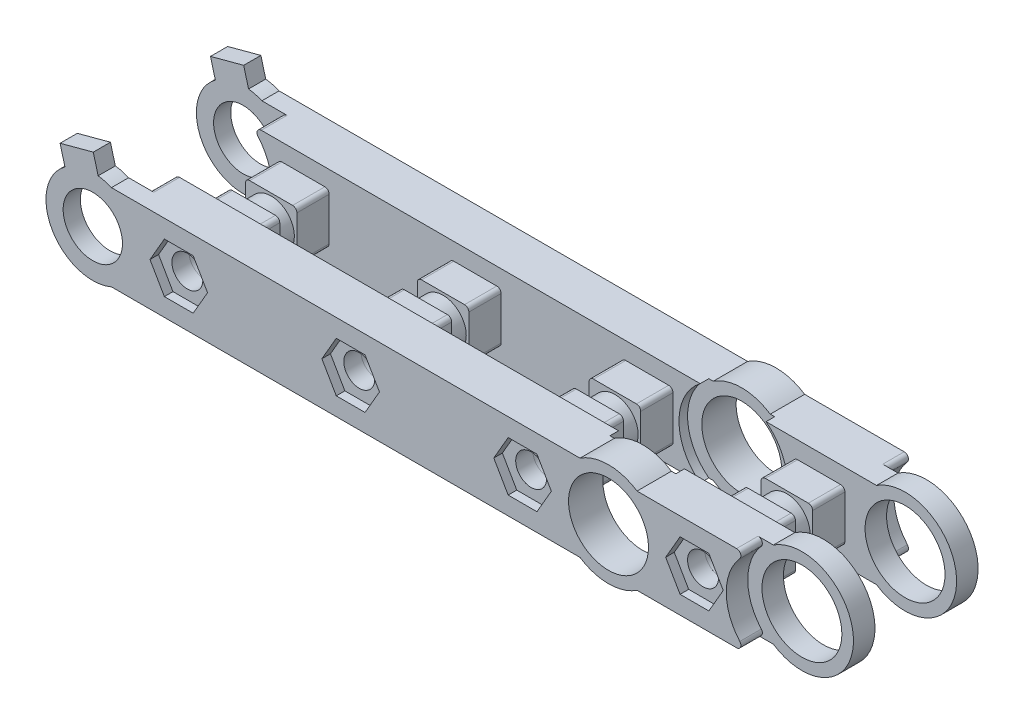
from build123d import *

# Parameters (mm, degrees)
SKETCH_1_R               = 1.8
SKETCH_1_R_2             = 4.39
SKETCH_1_R_3             = 3.45
EXTRUDE_1_DEPTH          = 2
SKETCH_2_R               = 1.8
SKETCH_2_R_2             = 4.39
EXTRUDE_2_DEPTH          = 3
EXTRUDE_3_DEPTH          = 2
SKETCH_4_R               = 1.8
SKETCH_4_R_2             = 3.45
SKETCH_4_R_3             = 4.39
EXTRUDE_4_DEPTH          = 2
SKETCH_5_R               = 1.8
SKETCH_5_R_2             = 4.39
EXTRUDE_5_DEPTH          = 3
SKETCH_12_R              = 6.3
CUT_EXTRUDE_5_DEPTH      = 2.5
SKETCH_14_R              = 6.3
CUT_EXTRUDE_7_DEPTH      = 1
FILLET_1_R               = 0.5
SKETCH_15_R              = 6.3
CUT_EXTRUDE_8_DEPTH      = 2.5
SKETCH_16_R              = 6.3
CUT_EXTRUDE_9_DEPTH      = 1
FILLET_2_R               = 0.5
EXTRUDE_6_DEPTH          = 2
SKETCH_7_W               = 6.2
SKETCH_7_H               = 6.2
CUT_EXTRUDE_1_DEPTH      = 2
SKETCH_8_W               = 6
SKETCH_8_H               = 6
SKETCH_8_R               = 1.8
EXTRUDE_7_DEPTH          = 11.5
SKETCH_9_W               = 6
SKETCH_9_H               = 6
SKETCH_9_R               = 2.7
CUT_EXTRUDE_2_DEPTH      = 1
CUT_EXTRUDE_2_DEPTH_BACK = 1
CUT_EXTRUDE_3_DEPTH      = 1
SKETCH_11_R              = 3.25
CUT_EXTRUDE_4_DEPTH      = 1.5
SKETCH_17_R              = 4.65
CUT_EXTRUDE_10_DEPTH     = 20.5
SKETCH_18_R              = 6.3
CUT_EXTRUDE_11_DEPTH     = 1
SKETCH_19_R              = 6.3
CUT_EXTRUDE_12_DEPTH     = 1
EXTRUDE_8_DEPTH          = 4
EXTRUDE_9_DEPTH          = 4
SKETCH_22_R              = 4.39
EXTRUDE_10_DEPTH         = 1
SKETCH_23_R              = 4.39
EXTRUDE_11_DEPTH         = 1
FILLET_3_R               = 0.5
SKETCH_24_R              = 4.65
CUT_EXTRUDE_13_DEPTH     = 18


with BuildPart() as part:
    # ｽｹｯﾁ1 → ﾎﾞｽ - 押し出し1 (new body)
    with BuildSketch(Plane.XY):
        with BuildLine():
            Line((-77.831475156, 5), (-60, 5))
            Line((-60, 5), (-40, 5))
            Line((-40, 5), (-20, 5))
            Line((-20, 5), (-3.31662479, 5))
            ThreePointArc((-3.31662479, 5), (6, 0), (-3.31662479, -5))
            Line((-3.31662479, -5), (-20, -5))
            Line((-20, -5), (-40, -5))
            Line((-40, -5), (-60, -5))
            Line((-60, -5), (-77.831475156, -5))
            ThreePointArc((-77.831475156, -5), (-85.45, 0), (-77.831475156, 5))
        make_face()
        with Locations((-10, 0)):
            Circle(SKETCH_1_R, mode=Mode.SUBTRACT)
        with Locations((-30, 0)):
            Circle(SKETCH_1_R, mode=Mode.SUBTRACT)
        with Locations((-50, 0)):
            Circle(SKETCH_1_R, mode=Mode.SUBTRACT)
        with Locations((-70, 0)):
            Circle(SKETCH_1_R, mode=Mode.SUBTRACT)
        Circle(SKETCH_1_R_2, mode=Mode.SUBTRACT)
        with Locations((-80, 0)):
            Circle(SKETCH_1_R_3, mode=Mode.SUBTRACT)
    extrude(amount=EXTRUDE_1_DEPTH)

    # ｽｹｯﾁ2 → ﾎﾞｽ - 押し出し2 (add)
    with BuildSketch(Plane(origin=(0, 0, 0), x_dir=(-1, 0, 0), z_dir=(0, 0, -1))):
        with BuildLine():
            Line((74.901961161, 5), (60, 5))
            Line((60, 5), (40, 5))
            Line((40, 5), (20, 5))
            Line((20, 5), (3.31662479, 5))
            ThreePointArc((3.31662479, 5), (-6, 0), (3.31662479, -5))
            Line((3.31662479, -5), (20, -5))
            Line((20, -5), (40, -5))
            Line((40, -5), (60, -5))
            Line((60, -5), (74.901961161, -5))
            ThreePointArc((74.901961161, -5), (75.357724903, -4.70561958), (75.276816958, -4.169117647))
            ThreePointArc((75.276816958, -4.169117647), (73.7, 0), (75.276816958, 4.169117647))
            ThreePointArc((75.276816958, 4.169117647), (75.357724903, 4.70561958), (74.901961161, 5))
        make_face()
        with Locations((30, 0)):
            Circle(SKETCH_2_R, mode=Mode.SUBTRACT)
        with Locations((10, 0)):
            Circle(SKETCH_2_R, mode=Mode.SUBTRACT)
        with Locations((70, 0)):
            Circle(SKETCH_2_R, mode=Mode.SUBTRACT)
        with Locations((50, 0)):
            Circle(SKETCH_2_R, mode=Mode.SUBTRACT)
        Circle(SKETCH_2_R_2, mode=Mode.SUBTRACT)
    extrude(amount=EXTRUDE_2_DEPTH)

    # ｽｹｯﾁ3 → ﾎﾞｽ - 押し出し3 (add)
    with BuildSketch(Plane.XY.offset(2)):
        Polygon((-79.944586424, 7.520600331), (-79.012837862, 4.043267356), (-82.876541167, 3.007991176), (-83.80828973, 6.48532415), align=None)
    extrude(amount=-EXTRUDE_3_DEPTH)

    # ｽｹｯﾁ12 → ｶｯﾄ - 押し出し5 (cut)
    with BuildSketch(Plane.XY.offset(2)):
        Circle(SKETCH_12_R)
    extrude(amount=-CUT_EXTRUDE_5_DEPTH, mode=Mode.SUBTRACT)

    # ｽｹｯﾁ14 → ｶｯﾄ - 押し出し7 (cut)
    with BuildSketch(Plane(origin=(0, 0, -3), x_dir=(-1, 0, 0), z_dir=(0, 0, -1))):
        Circle(SKETCH_14_R)
    extrude(amount=-CUT_EXTRUDE_7_DEPTH, mode=Mode.SUBTRACT)

    # ﾌｨﾚｯﾄ1
    fillet_1_edges = [part.edges().sort_by_distance(p)[0] for p in [
        (-3.832753579, -5, 0.75),
        (-3.832753579, 5, 0.75),
        (-3.832753579, 5, -2.5),
        (-3.832753579, -5, -2.5),
    ]]
    fillet(fillet_1_edges, radius=FILLET_1_R)

    # ｽｹｯﾁ7 → ｶｯﾄ - 押し出し1 (cut)
    with BuildSketch(Plane(origin=(0, 0, -3), x_dir=(-1, 0, 0), z_dir=(0, 0, -1))):
        with Locations((30, 0)):
            Rectangle(SKETCH_7_W, SKETCH_7_H)
        with Locations((10, 0)):
            Rectangle(SKETCH_7_W, SKETCH_7_H)
        with Locations((50, 0)):
            Rectangle(SKETCH_7_W, SKETCH_7_H)
        with Locations((70, 0)):
            Rectangle(SKETCH_7_W, SKETCH_7_H)
    extrude(amount=-CUT_EXTRUDE_1_DEPTH, mode=Mode.SUBTRACT)

    # ｽｹｯﾁ10 → ｶｯﾄ - 押し出し3 (cut)
    with BuildSketch(Plane.XY.offset(2)):
        Polygon((-11.674315781, 2.9), (-13.348631561, 0), (-11.674315781, -2.9), (-8.325684219, -2.9), (-6.651368439, 0), (-8.325684219, 2.9), align=None)
        Polygon((-31.674315781, -2.9), (-28.325684219, -2.9), (-26.651368439, 0), (-28.325684219, 2.9), (-31.674315781, 2.9), (-33.348631561, 0), align=None)
        Polygon((-51.674315781, -2.9), (-48.325684219, -2.9), (-46.651368439, 0), (-48.325684219, 2.9), (-51.674315781, 2.9), (-53.348631561, 0), align=None)
        Polygon((-68.325684219, -2.9), (-66.651368439, 0), (-68.325684219, 2.9), (-71.674315781, 2.9), (-73.348631561, 0), (-71.674315781, -2.9), align=None)
    extrude(amount=-CUT_EXTRUDE_3_DEPTH, mode=Mode.SUBTRACT)


with BuildPart() as body_2:
    # ｽｹｯﾁ4 → ﾎﾞｽ - 押し出し4 (new body)
    with BuildSketch(Plane.XY.offset(-17.5)):
        with BuildLine():
            Line((-60, 5), (-77.831475156, 5))
            ThreePointArc((-77.831475156, 5), (-85.45, 0), (-77.831475156, -5))
            Line((-77.831475156, -5), (-60, -5))
            Line((-60, -5), (-40, -5))
            Line((-40, -5), (-20, -5))
            Line((-20, -5), (-3.31662479, -5))
            ThreePointArc((-3.31662479, -5), (6, 0), (-3.31662479, 5))
            Line((-3.31662479, 5), (-20, 5))
            Line((-20, 5), (-40, 5))
            Line((-40, 5), (-60, 5))
        make_face()
        with Locations((-30, 0)):
            Circle(SKETCH_4_R, mode=Mode.SUBTRACT)
        with Locations((-10, 0)):
            Circle(SKETCH_4_R, mode=Mode.SUBTRACT)
        with Locations((-80, 0)):
            Circle(SKETCH_4_R_2, mode=Mode.SUBTRACT)
        with Locations((-70, 0)):
            Circle(SKETCH_4_R, mode=Mode.SUBTRACT)
        with Locations((-50, 0)):
            Circle(SKETCH_4_R, mode=Mode.SUBTRACT)
        Circle(SKETCH_4_R_3, mode=Mode.SUBTRACT)
    extrude(amount=EXTRUDE_4_DEPTH)

    # ｽｹｯﾁ5 → ﾎﾞｽ - 押し出し5 (add)
    with BuildSketch(Plane.XY.offset(-15.5)):
        with BuildLine():
            Line((-74.901961161, -5), (-60, -5))
            Line((-60, -5), (-40, -5))
            Line((-40, -5), (-20, -5))
            Line((-20, -5), (-3.31662479, -5))
            ThreePointArc((-3.31662479, -5), (6, 0), (-3.31662479, 5))
            Line((-3.31662479, 5), (-20, 5))
            Line((-20, 5), (-40, 5))
            Line((-40, 5), (-60, 5))
            Line((-60, 5), (-74.901961161, 5))
            ThreePointArc((-74.901961161, 5), (-75.357724903, 4.70561958), (-75.276816958, 4.169117647))
            ThreePointArc((-75.276816958, 4.169117647), (-73.7, 0), (-75.276816958, -4.169117647))
            ThreePointArc((-75.276816958, -4.169117647), (-75.357724903, -4.70561958), (-74.901961161, -5))
        make_face()
        with Locations((-10, 0)):
            Circle(SKETCH_5_R, mode=Mode.SUBTRACT)
        with Locations((-30, 0)):
            Circle(SKETCH_5_R, mode=Mode.SUBTRACT)
        with Locations((-50, 0)):
            Circle(SKETCH_5_R, mode=Mode.SUBTRACT)
        with Locations((-70, 0)):
            Circle(SKETCH_5_R, mode=Mode.SUBTRACT)
        Circle(SKETCH_5_R_2, mode=Mode.SUBTRACT)
    extrude(amount=EXTRUDE_5_DEPTH)

    # ｽｹｯﾁ15 → ｶｯﾄ - 押し出し8 (cut)
    with BuildSketch(Plane(origin=(0, 0, -17.5), x_dir=(-1, 0, 0), z_dir=(0, 0, -1))):
        Circle(SKETCH_15_R)
    extrude(amount=-CUT_EXTRUDE_8_DEPTH, mode=Mode.SUBTRACT)

    # ｽｹｯﾁ16 → ｶｯﾄ - 押し出し9 (cut)
    with BuildSketch(Plane.XY.offset(-12.5)):
        Circle(SKETCH_16_R)
    extrude(amount=-CUT_EXTRUDE_9_DEPTH, mode=Mode.SUBTRACT)

    # ﾌｨﾚｯﾄ2
    fillet_2_edges = [body_2.edges().sort_by_distance(p)[0] for p in [
        (-3.832753579, -5, -16.25),
        (-3.832753579, -5, -13),
        (-3.832753579, 5, -13),
        (-3.832753579, 5, -16.25),
    ]]
    fillet(fillet_2_edges, radius=FILLET_2_R)

    # ｽｹｯﾁ6 → ﾎﾞｽ - 押し出し6 (add)
    with BuildSketch(Plane(origin=(0, 0, -17.5), x_dir=(-1, 0, 0), z_dir=(0, 0, -1))):
        Polygon((79.944586424, 7.520600331), (79.012837862, 4.043267356), (82.876541167, 3.007991176), (83.80828973, 6.48532415), align=None)
    extrude(amount=-EXTRUDE_6_DEPTH)

    # ｽｹｯﾁ8 → ﾎﾞｽ - 押し出し7 (add)
    with BuildSketch(Plane.XY.offset(-12.5)):
        with Locations((-10, 0)):
            Rectangle(SKETCH_8_W, SKETCH_8_H)
        with Locations((-10, 0)):
            Circle(SKETCH_8_R, mode=Mode.SUBTRACT)
        with Locations((-30, 0)):
            Rectangle(SKETCH_8_W, SKETCH_8_H)
        with Locations((-30, 0)):
            Circle(SKETCH_8_R, mode=Mode.SUBTRACT)
        with Locations((-70, 0)):
            Rectangle(SKETCH_8_W, SKETCH_8_H)
        with Locations((-70, 0)):
            Circle(SKETCH_8_R, mode=Mode.SUBTRACT)
        with Locations((-50, 0)):
            Rectangle(SKETCH_8_W, SKETCH_8_H)
        with Locations((-50, 0)):
            Circle(SKETCH_8_R, mode=Mode.SUBTRACT)
    extrude(amount=EXTRUDE_7_DEPTH)

    # ｽｹｯﾁ9 → ｶｯﾄ - 押し出し2 (cut, two sides)
    with BuildSketch(Plane.XY.offset(-7.75)) as cut_extrude_2_sk:
        with Locations((-30, 0)):
            Rectangle(SKETCH_9_W, SKETCH_9_H)
        with Locations((-30, 0)):
            Circle(SKETCH_9_R, mode=Mode.SUBTRACT)
        with Locations((-10, 0)):
            Rectangle(SKETCH_9_W, SKETCH_9_H)
        with Locations((-10, 0)):
            Circle(SKETCH_9_R, mode=Mode.SUBTRACT)
        with Locations((-50, 0)):
            Rectangle(SKETCH_9_W, SKETCH_9_H)
        with Locations((-50, 0)):
            Circle(SKETCH_9_R, mode=Mode.SUBTRACT)
        with Locations((-70, 0)):
            Rectangle(SKETCH_9_W, SKETCH_9_H)
        with Locations((-70, 0)):
            Circle(SKETCH_9_R, mode=Mode.SUBTRACT)
    extrude(amount=CUT_EXTRUDE_2_DEPTH, mode=Mode.SUBTRACT)
    extrude(cut_extrude_2_sk.sketch, amount=-CUT_EXTRUDE_2_DEPTH_BACK, mode=Mode.SUBTRACT)

    # ｽｹｯﾁ11 → ｶｯﾄ - 押し出し4 (cut)
    with BuildSketch(Plane(origin=(0, 0, -17.5), x_dir=(-1, 0, 0), z_dir=(0, 0, -1))):
        with Locations((10, 0)):
            Circle(SKETCH_11_R)
        with Locations((30, 0)):
            Circle(SKETCH_11_R)
        with Locations((50, 0)):
            Circle(SKETCH_11_R)
        with Locations((70, 0)):
            Circle(SKETCH_11_R)
    extrude(amount=-CUT_EXTRUDE_4_DEPTH, mode=Mode.SUBTRACT)


with BuildPart() as cut_extrude_10_tool:
    # ｽｹｯﾁ17 → ｶｯﾄ - 押し出し10 (new body, through all)
    with BuildSketch(Plane.XY.offset(2)):
        with Locations((-20, 0)):
            Circle(SKETCH_17_R)
    extrude(amount=-CUT_EXTRUDE_10_DEPTH)


with BuildPart() as part_1:
    add(part.part)

    # ｶｯﾄ - 押し出し10: cut by cut_extrude_10_tool
    add(cut_extrude_10_tool.part, mode=Mode.SUBTRACT)

    # ｽｹｯﾁ18 → ｶｯﾄ - 押し出し11 (cut)
    with BuildSketch(Plane(origin=(0, 0, -3), x_dir=(-1, 0, 0), z_dir=(0, 0, -1))):
        with Locations((20, 0)):
            Circle(SKETCH_18_R)
    extrude(amount=-CUT_EXTRUDE_11_DEPTH, mode=Mode.SUBTRACT)

    # ｽｹｯﾁ21 → ﾎﾞｽ - 押し出し9 (add)
    with BuildSketch(Plane(origin=(0, 0, -2), x_dir=(-1, 0, 0), z_dir=(0, 0, -1))):
        with BuildLine():
            Line((23.31662479, -5), (16.68337521, -5))
            ThreePointArc((16.68337521, -5), (20, -6), (23.31662479, -5))
        make_face()
        with BuildLine():
            Line((16.68337521, 5), (23.31662479, 5))
            ThreePointArc((23.31662479, 5), (20, 6), (16.68337521, 5))
        make_face()
    extrude(amount=-EXTRUDE_9_DEPTH)

    # ｽｹｯﾁ22 → ﾎﾞｽ - 押し出し10 (add)
    with BuildSketch(Plane(origin=(0, 0, -2), x_dir=(-1, 0, 0), z_dir=(0, 0, -1))):
        with BuildLine():
            Line((5.098038839, 5), (3.31662479, 5))
            ThreePointArc((3.31662479, 5), (-6, 0), (3.31662479, -5))
            Line((3.31662479, -5), (5.098038839, -5))
            ThreePointArc((5.098038839, -5), (4.642275097, -4.70561958), (4.723183042, -4.169117647))
            ThreePointArc((4.723183042, -4.169117647), (6.3, 0), (4.723183042, 4.169117647))
            ThreePointArc((4.723183042, 4.169117647), (4.642275097, 4.70561958), (5.098038839, 5))
        make_face()
        Circle(SKETCH_22_R, mode=Mode.SUBTRACT)
    extrude(amount=EXTRUDE_10_DEPTH)


with BuildPart() as body_2_1:
    add(body_2.part)

    # ｶｯﾄ - 押し出し10: cut by cut_extrude_10_tool
    add(cut_extrude_10_tool.part, mode=Mode.SUBTRACT)

    # ｽｹｯﾁ19 → ｶｯﾄ - 押し出し12 (cut)
    with BuildSketch(Plane.XY.offset(-12.5)):
        with Locations((-20, 0)):
            Circle(SKETCH_19_R)
    extrude(amount=-CUT_EXTRUDE_12_DEPTH, mode=Mode.SUBTRACT)

    # ｽｹｯﾁ20 → ﾎﾞｽ - 押し出し8 (add)
    with BuildSketch(Plane.XY.offset(-13.5)):
        with BuildLine():
            Line((-23.31662479, 5), (-16.68337521, 5))
            ThreePointArc((-16.68337521, 5), (-20, 6), (-23.31662479, 5))
        make_face()
        with BuildLine():
            Line((-23.31662479, -5), (-16.68337521, -5))
            ThreePointArc((-16.68337521, -5), (-20, -6), (-23.31662479, -5))
        make_face()
    extrude(amount=-EXTRUDE_8_DEPTH)

    # ｽｹｯﾁ23 → ﾎﾞｽ - 押し出し11 (add)
    with BuildSketch(Plane.XY.offset(-13.5)):
        with BuildLine():
            Line((-3.31662479, 5), (-5.098038839, 5))
            ThreePointArc((-5.098038839, 5), (-4.642275097, 4.70561958), (-4.723183042, 4.169117647))
            ThreePointArc((-4.723183042, 4.169117647), (-6.3, 0), (-4.723183042, -4.169117647))
            ThreePointArc((-4.723183042, -4.169117647), (-4.642275097, -4.70561958), (-5.098038839, -5))
            Line((-5.098038839, -5), (-3.31662479, -5))
            ThreePointArc((-3.31662479, -5), (6, 0), (-3.31662479, 5))
        make_face()
        Circle(SKETCH_23_R, mode=Mode.SUBTRACT)
    extrude(amount=EXTRUDE_11_DEPTH)

    # ﾌｨﾚｯﾄ3
    fillet_3_edges = [body_2_1.edges().sort_by_distance(p)[0] for p in [
        (-7, 3, -3.875),
        (-7, -3, -3.875),
        (-13, -3, -3.875),
        (-13, 3, -3.875),
        (-33, 3, -3.875),
        (-27, 3, -3.875),
        (-27, -3, -3.875),
        (-33, -3, -3.875),
        (-73, 3, -3.875),
        (-67, 3, -3.875),
        (-67, -3, -3.875),
        (-73, -3, -3.875),
        (-53, 3, -3.875),
        (-47, 3, -3.875),
        (-47, -3, -3.875),
        (-53, -3, -3.875),
        (-53, -3, -10.625),
        (-47, -3, -10.625),
        (-47, 3, -10.625),
        (-53, 3, -10.625),
        (-73, -3, -10.625),
        (-67, -3, -10.625),
        (-67, 3, -10.625),
        (-73, 3, -10.625),
        (-33, -3, -10.625),
        (-27, -3, -10.625),
        (-27, 3, -10.625),
        (-33, 3, -10.625),
        (-13, 3, -10.625),
        (-13, -3, -10.625),
        (-7, -3, -10.625),
        (-7, 3, -10.625),
    ]]
    fillet(fillet_3_edges, radius=FILLET_3_R)


with BuildPart() as cut_extrude_13_tool:
    # ｽｹｯﾁ24 → ｶｯﾄ - 押し出し13 (new body, through all)
    with BuildSketch(Plane.XY.offset(-0.5)):
        Circle(SKETCH_24_R)
    extrude(amount=-CUT_EXTRUDE_13_DEPTH)


with BuildPart() as part_2:
    add(part_1.part)

    # ｶｯﾄ - 押し出し13: cut by cut_extrude_13_tool
    add(cut_extrude_13_tool.part, mode=Mode.SUBTRACT)


with BuildPart() as body_2_2:
    add(body_2_1.part)

    # ｶｯﾄ - 押し出し13: cut by cut_extrude_13_tool
    add(cut_extrude_13_tool.part, mode=Mode.SUBTRACT)


solid = Compound([part_2.part, body_2_2.part])
